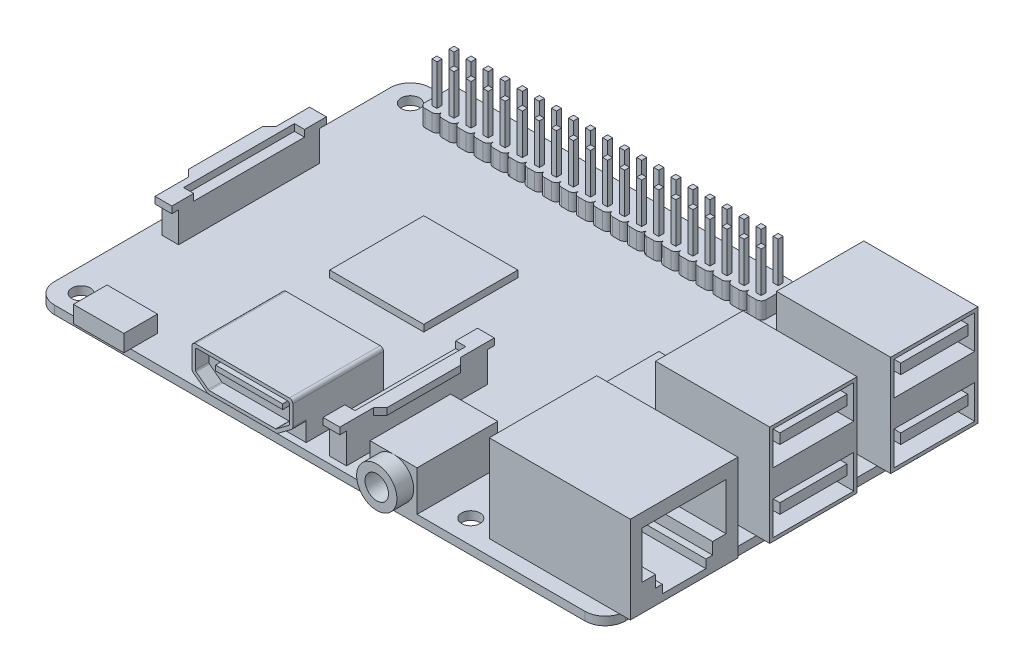
from build123d import *

# Parameters (mm, degrees)
SKETCH1_R            = 1.375
BOSS_EXTRUDE1_DEPTH  = 1.25
SKETCH4_W            = 17
SKETCH4_H            = 13
BOSS_EXTRUDE6_DEPTH  = 15
SKETCH21_W           = 12
SKETCH21_H           = 5
SKETCH21_W_2         = 10
SKETCH21_H_2         = 1.5
CUT_EXTRUDE7_DEPTH   = 13
SKETCH2_W            = 14
SKETCH2_H            = 14
SKETCH2_W_2          = 9
SKETCH2_H_2          = 9
BOSS_EXTRUDE5_DEPTH  = 1
SKETCH5_W            = 21
SKETCH5_H            = 16
BOSS_EXTRUDE7_DEPTH  = 13
CUT_EXTRUDE6_DEPTH   = 13
BOSS_EXTRUDE9_DEPTH  = 2.5
SKETCH9_W            = 0.75
SKETCH9_H            = 0.75
BOSS_EXTRUDE10_DEPTH = 6
LPATTERN1_COUNT      = 20
LPATTERN1_PITCH      = 2.54
SKETCH10_W           = 2.5
SKETCH10_H           = 21
BOSS_EXTRUDE11_DEPTH = 4.5
BOSS_EXTRUDE12_DEPTH = 1
SKETCH12_W           = 7
SKETCH12_H           = 12
BOSS_EXTRUDE13_DEPTH = 6
SKETCH13_R           = 3
BOSS_EXTRUDE14_DEPTH = 2.5
CUT_EXTRUDE1_REACH   = 60.5
SKETCH14_R           = 1.75
SKETCH15_W           = 7.5
SKETCH15_H           = 5
BOSS_EXTRUDE15_DEPTH = 2.5
SKETCH17_W           = 15
SKETCH17_H           = 11.5
BOSS_EXTRUDE16_DEPTH = 6.5
FILLET1_R            = 0.5
BOSS_EXTRUDE17_DEPTH = 2
SKETCH22_W           = 12
SKETCH22_H           = 12
BOSS_EXTRUDE18_DEPTH = 1
SKETCH23_W           = 10
SKETCH23_H           = 0.75
BOSS_EXTRUDE19_DEPTH = 1
SKETCH24_W           = 11
SKETCH24_H           = 12
BOSS_EXTRUDE20_DEPTH = 1.25
SKETCH25_W           = 11.5
SKETCH25_H           = 0.75
CUT_EXTRUDE8_DEPTH   = 9
CUT_EXTRUDE9_DEPTH   = 0.25


with BuildPart() as part:
    # Sketch1 → Boss-Extrude1 (new body)
    with BuildSketch(Plane(origin=(0, 0, 0), x_dir=(1, 0, 0), z_dir=(0, 1, 0))):
        with BuildLine():
            Line((-0.5, 52.5), (78.5, 52.5))
            ThreePointArc((78.5, 52.5), (80.621320344, 51.621320344), (81.5, 49.5))
            Line((81.5, 49.5), (81.5, -0.5))
            ThreePointArc((81.5, -0.5), (80.621320344, -2.621320344), (78.5, -3.5))
            Line((78.5, -3.5), (-0.5, -3.5))
            ThreePointArc((-0.5, -3.5), (-2.621320344, -2.621320344), (-3.5, -0.5))
            Line((-3.5, -0.5), (-3.5, 49.5))
            ThreePointArc((-3.5, 49.5), (-2.621320344, 51.621320344), (-0.5, 52.5))
        make_face()
        with Locations((58, 49)):
            Circle(SKETCH1_R, mode=Mode.SUBTRACT)
        with Locations((0, 49)):
            Circle(SKETCH1_R, mode=Mode.SUBTRACT)
        Circle(SKETCH1_R, mode=Mode.SUBTRACT)
        with Locations((58, 0)):
            Circle(SKETCH1_R, mode=Mode.SUBTRACT)
    extrude(amount=BOSS_EXTRUDE1_DEPTH)

    # Sketch4 → Boss-Extrude6 (add)
    with BuildSketch(Plane(origin=(0, 1.25, 0), x_dir=(1, 0, 0), z_dir=(0, 1, 0))):
        with Locations((75, 43.5)):
            Rectangle(SKETCH4_W, SKETCH4_H)
        with Locations((75, 25.5)):
            Rectangle(SKETCH4_W, SKETCH4_H)
    extrude(amount=BOSS_EXTRUDE6_DEPTH)

    # Sketch21 → Cut-Extrude7 (cut)
    with BuildSketch(Plane(origin=(83.5, 0, 0), x_dir=(0, 0, -1), z_dir=(1, 0, 0))):
        with Locations((25.5, 13.25)):
            Rectangle(SKETCH21_W, SKETCH21_H)
        with Locations((25.5, 14)):
            Rectangle(SKETCH21_W_2, SKETCH21_H_2, mode=Mode.SUBTRACT)
        with Locations((25.5, 4.25)):
            Rectangle(SKETCH21_W, SKETCH21_H)
        with Locations((25.5, 5)):
            Rectangle(SKETCH21_W_2, SKETCH21_H_2, mode=Mode.SUBTRACT)
        with Locations((43.5, 4.25)):
            Rectangle(SKETCH21_W, SKETCH21_H)
        with Locations((43.5, 5)):
            Rectangle(SKETCH21_W_2, SKETCH21_H_2, mode=Mode.SUBTRACT)
        with Locations((43.5, 13.25)):
            Rectangle(SKETCH21_W, SKETCH21_H)
        with Locations((43.5, 14)):
            Rectangle(SKETCH21_W_2, SKETCH21_H_2, mode=Mode.SUBTRACT)
    extrude(amount=-CUT_EXTRUDE7_DEPTH, mode=Mode.SUBTRACT)

    # Sketch2 → Boss-Extrude5 (add)
    with BuildSketch(Plane.XZ.offset(-1.25)):
        with Locations((23.5, -27.5)):
            Rectangle(SKETCH2_W, SKETCH2_H)
        with Locations((56, -30)):
            Rectangle(SKETCH2_W_2, SKETCH2_H_2)
    extrude(amount=-BOSS_EXTRUDE5_DEPTH)

    # Sketch5 → Boss-Extrude7 (add)
    with BuildSketch(Plane(origin=(0, 1.25, 0), x_dir=(1, 0, 0), z_dir=(0, 1, 0))):
        with Locations((72.5, 6.75)):
            Rectangle(SKETCH5_W, SKETCH5_H)
    extrude(amount=BOSS_EXTRUDE7_DEPTH)

    # Sketch20 → Cut-Extrude6 (cut)
    with BuildSketch(Plane(origin=(83, 0, 0), x_dir=(0, 0, -1), z_dir=(1, 0, 0))):
        Polygon((13, 12.25), (0.5, 12.25), (0.5, 5.25), (2.5, 5.25), (2.5, 3.5), (3.5, 3.5), (3.5, 2.25), (10, 2.25), (10, 3.5), (11, 3.5), (11, 5.25), (13, 5.25), align=None)
    extrude(amount=-CUT_EXTRUDE6_DEPTH, mode=Mode.SUBTRACT)

    # Sketch8 → Boss-Extrude9 (add)
    with BuildSketch(Plane(origin=(0, 1.25, 0), x_dir=(1, 0, 0), z_dir=(0, 1, 0))):
        with BuildLine():
            Line((4.25, 52), (5.29, 52))
            ThreePointArc((5.29, 52), (5.820330086, 51.780330086), (6.04, 51.25))
            Line((6.04, 51.25), (6.04, 47.67))
            ThreePointArc((6.04, 47.67), (5.820330086, 47.139669914), (5.29, 46.92))
            Line((5.29, 46.92), (4.25, 46.92))
            ThreePointArc((4.25, 46.92), (3.719669914, 47.139669914), (3.5, 47.67))
            Line((3.5, 47.67), (3.5, 51.25))
            ThreePointArc((3.5, 51.25), (3.719669914, 51.780330086), (4.25, 52))
        make_face()
    boss_extrude9 = extrude(amount=BOSS_EXTRUDE9_DEPTH)

    # Sketch9 → Boss-Extrude10 (add)
    with BuildSketch(Plane(origin=(0, 3.75, 0), x_dir=(1, 0, 0), z_dir=(0, 1, 0))):
        with Locations((4.77, 50.73)):
            Rectangle(SKETCH9_W, SKETCH9_H)
        with Locations((4.77, 48.19)):
            Rectangle(SKETCH9_W, SKETCH9_H)
    boss_extrude10 = extrude(amount=BOSS_EXTRUDE10_DEPTH)

    # LPattern1: Boss-Extrude9, Boss-Extrude10 ×20
    with Locations(*[(i * LPATTERN1_PITCH, 0, 0) for i in range(1, LPATTERN1_COUNT)]):
        add(boss_extrude9)
        add(boss_extrude10)

    # Sketch10 → Boss-Extrude11 (add)
    with BuildSketch(Plane(origin=(0, 1.25, 0), x_dir=(1, 0, 0), z_dir=(0, 1, 0))):
        with Locations((-0.25, 24)):
            Rectangle(SKETCH10_W, SKETCH10_H)
        with Locations((40.75, 8)):
            Rectangle(SKETCH10_W, SKETCH10_H)
    extrude(amount=BOSS_EXTRUDE11_DEPTH)

    # Sketch11 → Boss-Extrude12 (add)
    with BuildSketch(Plane(origin=(0, 5.75, 0), x_dir=(1, 0, 0), z_dir=(0, 1, 0))):
        Polygon((1, 35.5), (-1.5, 35.5), (-1.5, 30.5), (-2.5, 29.5), (-2.5, 18.5), (-1.5, 17.5), (-1.5, 12.5), (1, 12.5), (1, 15.75), (-0.5, 15.75), (-0.5, 32.25), (1, 32.25), align=None)
        Polygon((39.5, 19.5), (39.5, 16.25), (41, 16.25), (41, -0.25), (39.5, -0.25), (39.5, -3.5), (42, -3.5), (42, 1.5), (43, 2.5), (43, 13.5), (42, 14.5), (42, 19.5), align=None)
    extrude(amount=BOSS_EXTRUDE12_DEPTH)

    # Sketch12 → Boss-Extrude13 (add)
    with BuildSketch(Plane(origin=(0, 1.25, 0), x_dir=(1, 0, 0), z_dir=(0, 1, 0))):
        with Locations((50, 2.5)):
            Rectangle(SKETCH12_W, SKETCH12_H)
    extrude(amount=BOSS_EXTRUDE13_DEPTH)

    # Sketch13 → Boss-Extrude14 (add)
    with BuildSketch(Plane.XY.offset(3.5)):
        with Locations((50, 4.25)):
            Circle(SKETCH13_R)
    extrude(amount=BOSS_EXTRUDE14_DEPTH)

    # Sketch14 → Cut-Extrude1 (cut, up to next)
    with BuildSketch(Plane.XY.offset(6), mode=Mode.PRIVATE) as cut_extrude1_sk1:
        with Locations((50, 4.25)):
            Circle(SKETCH14_R)
    cut_extrude1_tool1 = extrude(cut_extrude1_sk1.sketch, amount=-CUT_EXTRUDE1_REACH, mode=Mode.PRIVATE) & part.part
    add(cut_extrude1_tool1.solids().sort_by_distance((50, 4.25, 6))[0], mode=Mode.SUBTRACT)

    # Sketch17 → Boss-Extrude16 (add)
    with BuildSketch(Plane(origin=(0, 1.25, 0), x_dir=(1, 0, 0), z_dir=(0, 1, 0))):
        with Locations((28.5, 3.25)):
            Rectangle(SKETCH17_W, SKETCH17_H)
    extrude(amount=BOSS_EXTRUDE16_DEPTH)

    # Fillet1
    fillet1_edges = [part.edges().sort_by_distance(p)[0] for p in [
        (21, 7.75, -3.25),
        (36, 7.75, -3.25),
    ]]
    fillet(fillet1_edges, radius=FILLET1_R)

    # Sketch19 → Boss-Extrude17 (add)
    with BuildSketch(Plane.XY.offset(2.5)):
        with BuildLine():
            Line((21, 4.25), (21, 7.25))
            ThreePointArc((21, 7.25), (21.146446609, 7.603553391), (21.5, 7.75))
            Line((21.5, 7.75), (35.5, 7.75))
            ThreePointArc((35.5, 7.75), (35.853553391, 7.603553391), (36, 7.25))
            Line((36, 7.25), (36, 4.25))
            ThreePointArc((36, 4.25), (35.947213595, 4.026393202), (35.8, 3.85))
            Line((35.8, 3.85), (33.8, 2.35))
            ThreePointArc((33.8, 2.35), (33.658113883, 2.275658351), (33.5, 2.25))
            Line((33.5, 2.25), (23.5, 2.25))
            ThreePointArc((23.5, 2.25), (23.341886117, 2.275658351), (23.2, 2.35))
            Line((23.2, 2.35), (21.2, 3.85))
            ThreePointArc((21.2, 3.85), (21.052786405, 4.026393202), (21, 4.25))
        make_face()
        with BuildLine():
            Line((21.6, 4.175), (23.433333333, 2.8))
            ThreePointArc((23.433333333, 2.8), (23.504276392, 2.762829175), (23.583333333, 2.75))
            Line((23.583333333, 2.75), (33.416666667, 2.75))
            ThreePointArc((33.416666667, 2.75), (33.495723608, 2.762829175), (33.566666667, 2.8))
            Line((33.566666667, 2.8), (35.4, 4.175))
            ThreePointArc((35.4, 4.175), (35.473606798, 4.263196601), (35.5, 4.375))
            Line((35.5, 4.375), (35.5, 7))
            ThreePointArc((35.5, 7), (35.426776695, 7.176776695), (35.25, 7.25))
            Line((35.25, 7.25), (21.75, 7.25))
            ThreePointArc((21.75, 7.25), (21.573223305, 7.176776695), (21.5, 7))
            Line((21.5, 7), (21.5, 4.375))
            ThreePointArc((21.5, 4.375), (21.526393202, 4.263196601), (21.6, 4.175))
        make_face(mode=Mode.SUBTRACT)
    extrude(amount=BOSS_EXTRUDE17_DEPTH)

    # Sketch22 → Boss-Extrude18 (add)
    with BuildSketch(Plane.XZ):
        with Locations((39.5, -29.5)):
            Rectangle(SKETCH22_W, SKETCH22_H)
    extrude(amount=BOSS_EXTRUDE18_DEPTH)

    # Sketch23 → Boss-Extrude19 (add)
    with BuildSketch(Plane.XY.offset(2.5)):
        with Locations((28.5, 5.125)):
            Rectangle(SKETCH23_W, SKETCH23_H)
    extrude(amount=BOSS_EXTRUDE19_DEPTH)

    # Sketch24 → Boss-Extrude20 (add)
    with BuildSketch(Plane.XZ):
        with Locations((4, -24.5)):
            Rectangle(SKETCH24_W, SKETCH24_H)
    extrude(amount=BOSS_EXTRUDE20_DEPTH)

    # Sketch25 → Cut-Extrude8 (cut)
    with BuildSketch(Plane.ZY.offset(1.5)):
        with Locations((-24.5, -0.625)):
            Rectangle(SKETCH25_W, SKETCH25_H)
    extrude(amount=-CUT_EXTRUDE8_DEPTH, mode=Mode.SUBTRACT)

    # Sketch26 → Cut-Extrude9 (cut)
    with BuildSketch(Plane.XZ.offset(1.25)):
        with BuildLine():
            Line((-1.5, -20), (-0.5, -20))
            ThreePointArc((-0.5, -20), (-0.323223305, -20.073223305), (-0.25, -20.25))
            Line((-0.25, -20.25), (-0.25, -28.25))
            ThreePointArc((-0.25, -28.25), (-0.323223305, -28.426776695), (-0.5, -28.5))
            Line((-0.5, -28.5), (-1.5, -28.5))
            Line((-1.5, -28.5), (-1.5, -20))
        make_face()
    extrude(amount=-CUT_EXTRUDE9_DEPTH, mode=Mode.SUBTRACT)


with BuildPart() as body_2:
    # Sketch15 → Boss-Extrude15 (new body)
    with BuildSketch(Plane(origin=(0, 1.25, 0), x_dir=(1, 0, 0), z_dir=(0, 1, 0))):
        with Locations((7.1, -2)):
            Rectangle(SKETCH15_W, SKETCH15_H)
    extrude(amount=BOSS_EXTRUDE15_DEPTH)


solid = Compound([part.part, body_2.part])
